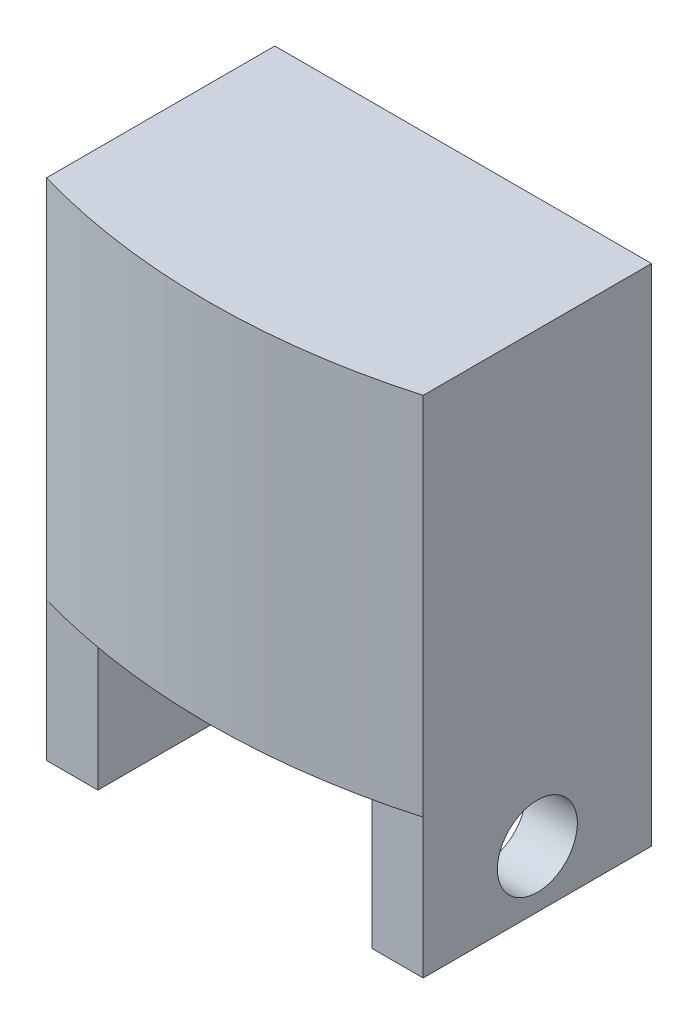
from build123d import *

# Parameters (mm, degrees)
BOSS_EXTRUDE1_DEPTH = 32
SKETCH3_W           = 20
SKETCH3_H           = 12.2
BOSS_EXTRUDE2_DEPTH = 4.5
SKETCH4_R           = 3.5
CUT_EXTRUDE1_DEPTH  = 34
SKETCH5_R           = 3.5
CUT_EXTRUDE2_DEPTH  = 9
FILLET1_R           = 2.5


with BuildPart() as part:
    # Sketch1 → Boss-Extrude1 (new body)
    with BuildSketch(Plane(origin=(0, 0, 0), x_dir=(1, 0, 0), z_dir=(0, 1, 0))):
        with BuildLine():
            Line((-16.5, 10), (16.5, 10))
            Line((16.5, 10), (16.5, -10))
            ThreePointArc((16.5, -10), (0, -12.313346431), (-16.5, -10))
            Line((-16.5, -10), (-16.5, 10))
        make_face()
    extrude(amount=BOSS_EXTRUDE1_DEPTH)

    # Sketch3 → Boss-Extrude2 (add)
    with BuildSketch(Plane.ZY.offset(16.5)):
        with Locations((0, -6.1)):
            Rectangle(SKETCH3_W, SKETCH3_H)
    boss_extrude2 = extrude(amount=-BOSS_EXTRUDE2_DEPTH)

    # Mirror1: Boss-Extrude2 across plane
    add(boss_extrude2.mirror(Plane(origin=(0, 0, 0), x_dir=(0, 0, 1), z_dir=(1, 0, 0))))

    # Sketch4 → Cut-Extrude1 (cut, through all)
    with BuildSketch(Plane.ZY.offset(16.5)):
        with Locations((0, -7.2)):
            Circle(SKETCH4_R)
    extrude(amount=-CUT_EXTRUDE1_DEPTH, mode=Mode.SUBTRACT)

    # Sketch5 → Cut-Extrude2 (cut)
    with BuildSketch(Plane.ZY.offset(16.5)):
        with Locations((0, 24.5)):
            Circle(SKETCH5_R)
    extrude(amount=-CUT_EXTRUDE2_DEPTH, mode=Mode.SUBTRACT)

    # Fillet1
    fillet1_edges = [part.edges().sort_by_distance(p)[0] for p in [
        (-12, -6.1, -10),
        (12, -6.1, -10),
    ]]
    fillet(fillet1_edges, radius=FILLET1_R)


solid = part.part
